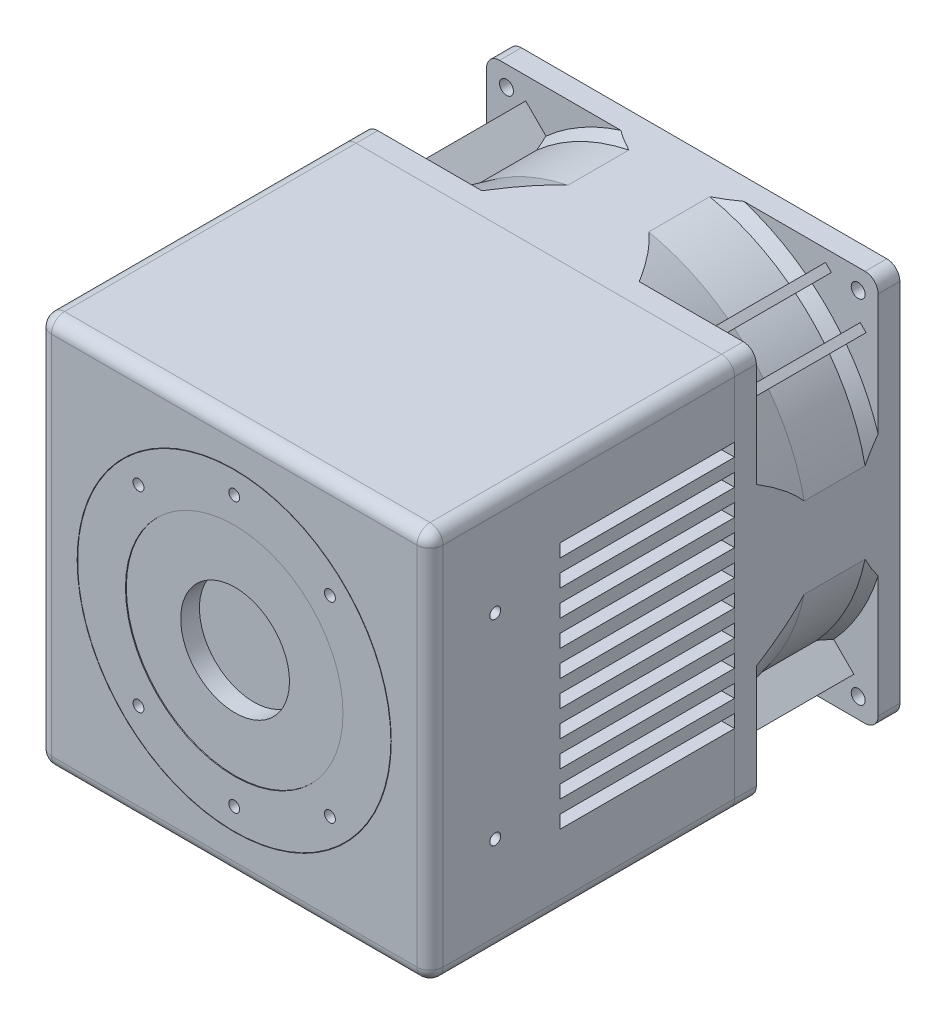
from build123d import *

# Parameters (mm, degrees)
EXTRUDE_1_DEPTH          = 70
SKETCH_4_W               = 40.152791685
SKETCH_4_H               = 3
CUT_EXTRUDE_1_DEPTH      = 89
SKETCH_5_R               = 1.25
CUT_EXTRUDE_2_DEPTH      = 8
SKETCH_6_R               = 1.25
CUT_EXTRUDE_4_DEPTH      = 12
FILLET_1_R               = 3
SKETCH_7_R               = 36.1
SKETCH_7_R_2             = 36
CUT_EXTRUDE_5_DEPTH      = 10
SKETCH_5_4_R             = 1.25
CUT_EXTRUDE_6_DEPTH      = 10
SKETCH_5_5_R             = 12.5
CUT_EXTRUDE_7_DEPTH      = 4.5
SKETCH_8_R               = 1.6
EXTRUDE_2_DEPTH          = 5
SKETCH_11_W              = 8.63890027
SKETCH_11_H              = 44.688652033
SKETCH_11_W_2            = 46.691504786
SKETCH_11_H_2            = 7.324528151
SKETCH_11_W_3            = 16.525132981
SKETCH_11_H_3            = 54.077024309
SKETCH_11_W_4            = 47.692931162
SKETCH_11_H_4            = 8.075597933
CUT_EXTRUDE_8_DEPTH      = 51
SKETCH_12_R              = 1.6
EXTRUDE_4_DEPTH          = 5
EXTRUDE_5_DEPTH          = 28
SKETCH_17_R              = 71.537562885
CUT_EXTRUDE_9_DEPTH      = 59
PATTERN_CIRCULAR_3_COUNT = 7
SKETCH_18_R              = 25
CUT_EXTRUDE_10_DEPTH     = 0.2


with BuildPart() as part:
    # Sketch 1 → Extrude 1 (new body)
    with BuildSketch(Plane.XY):
        with BuildLine():
            Line((-42, -45), (42, -45))
            ThreePointArc((42, -45), (44.121320344, -44.121320344), (45, -42))
            Line((45, -42), (45, 42))
            ThreePointArc((45, 42), (44.121320344, 44.121320344), (42, 45))
            Line((42, 45), (-42, 45))
            ThreePointArc((-42, 45), (-44.121320344, 44.121320344), (-45, 42))
            Line((-45, 42), (-45, -42))
            ThreePointArc((-45, -42), (-44.121320344, -44.121320344), (-42, -45))
        make_face()
    extrude(amount=EXTRUDE_1_DEPTH)

    # Sketch 4 → Cut-Extrude 1 (cut, symmetric)
    with BuildSketch(Plane(origin=(0, 0, 0), x_dir=(0, 0, -1), z_dir=(1, 0, 0))):
        with Locations((-20.076395843, 27.5)):
            Rectangle(SKETCH_4_W, SKETCH_4_H)
        with Locations((-20.076395843, 21.5)):
            Rectangle(SKETCH_4_W, SKETCH_4_H)
        with Locations((-20.076395843, 15.5)):
            Rectangle(SKETCH_4_W, SKETCH_4_H)
        with Locations((-20.076395843, 9.5)):
            Rectangle(SKETCH_4_W, SKETCH_4_H)
        with Locations((-20.076395843, 3.5)):
            Rectangle(SKETCH_4_W, SKETCH_4_H)
        with Locations((-20.076395843, -2.5)):
            Rectangle(SKETCH_4_W, SKETCH_4_H)
        with Locations((-20.076395843, -8.5)):
            Rectangle(SKETCH_4_W, SKETCH_4_H)
        with Locations((-20.076395843, -14.5)):
            Rectangle(SKETCH_4_W, SKETCH_4_H)
        with Locations((-20.076395843, -20.5)):
            Rectangle(SKETCH_4_W, SKETCH_4_H)
        with Locations((-20.076395843, -26.5)):
            Rectangle(SKETCH_4_W, SKETCH_4_H)
    extrude(amount=CUT_EXTRUDE_1_DEPTH, both=True, mode=Mode.SUBTRACT)

    # Sketch 5 → Cut-Extrude 2 (cut)
    with BuildSketch(Plane.XY.offset(70)):
        with Locations((0, 31)):
            Circle(SKETCH_5_R)
        with Locations((0, -31)):
            Circle(SKETCH_5_R)
    extrude(amount=-CUT_EXTRUDE_2_DEPTH, mode=Mode.SUBTRACT)

    # Sketch 6 → Cut-Extrude 4 (cut)
    with BuildSketch(Plane(origin=(45, 0, 0), x_dir=(0, 0, -1), z_dir=(1, 0, 0))):
        with Locations((-55, 22.5)):
            Circle(SKETCH_6_R)
        with Locations(Location((-55, -22.5, 0), (0, 0, 180))):  # turned: the seam where the file's is
            Circle(SKETCH_6_R)
    cut_extrude_4 = extrude(amount=-CUT_EXTRUDE_4_DEPTH, mode=Mode.SUBTRACT)

    # Mirror 1: Cut-Extrude 4 across plane
    add(cut_extrude_4.mirror(Plane(origin=(0, 0, 0), x_dir=(0, 0, 1), z_dir=(1, 0, 0))), mode=Mode.SUBTRACT)

    # Fillet 1
    fillet_1_edges = [part.edges().sort_by_distance(p)[0] for p in [
        (44.121320344, -44.121320344, 70),
        (45, 0, 70),
        (44.121320344, 44.121320344, 70),
        (0, 45, 70),
        (-44.121320344, 44.121320344, 70),
        (-45, 0, 70),
        (-44.121320344, -44.121320344, 70),
        (0, -45, 70),
    ]]
    fillet(fillet_1_edges, radius=FILLET_1_R)

    # Sketch 7 → Cut-Extrude 5 (cut)
    with BuildSketch(Plane.XY.offset(70)):
        Circle(SKETCH_7_R)
        Circle(SKETCH_7_R_2, mode=Mode.SUBTRACT)
    extrude(amount=-CUT_EXTRUDE_5_DEPTH, mode=Mode.SUBTRACT)

    # Sketch 5_4 → Cut-Extrude 6 (cut)
    with BuildSketch(Plane.XY.offset(70)):
        with Locations((-22, 22)):
            Circle(SKETCH_5_4_R)
        with Locations((22, 22)):
            Circle(SKETCH_5_4_R)
        with Locations((22, -22)):
            Circle(SKETCH_5_4_R)
        with Locations((-22, -22)):
            Circle(SKETCH_5_4_R)
    extrude(amount=-CUT_EXTRUDE_6_DEPTH, mode=Mode.SUBTRACT)

    # Sketch 5_5 → Cut-Extrude 7 (cut)
    with BuildSketch(Plane.XY.offset(70)):
        Circle(SKETCH_5_5_R)
    extrude(amount=-CUT_EXTRUDE_7_DEPTH, mode=Mode.SUBTRACT)

    # Sketch 18 → Cut-Extrude 10 (cut)
    with BuildSketch(Plane.XY.offset(70)):
        Circle(SKETCH_18_R)
    extrude(amount=-CUT_EXTRUDE_10_DEPTH, mode=Mode.SUBTRACT)


with BuildPart() as body_2:
    # Sketch 8 → Extrude 2 (new body)
    with BuildSketch(Plane(origin=(0, 0, 0), x_dir=(-1, 0, 0), z_dir=(0, 0, -1))):
        with BuildLine():
            Line((42, -45), (-42, -45))
            ThreePointArc((-42, -45), (-44.121320344, -44.121320344), (-45, -42))
            Line((-45, -42), (-45, 42))
            ThreePointArc((-45, 42), (-44.121320344, 44.121320344), (-42, 45))
            Line((-42, 45), (42, 45))
            ThreePointArc((42, 45), (44.121320344, 44.121320344), (45, 42))
            Line((45, 42), (45, -42))
            ThreePointArc((45, -42), (44.121320344, -44.121320344), (42, -45))
        make_face()
        with Locations((-40.415644678, 40.415644678)):
            Circle(SKETCH_8_R, mode=Mode.SUBTRACT)
        with Locations((40.415644678, 40.415644678)):
            Circle(SKETCH_8_R, mode=Mode.SUBTRACT)
        with Locations((40.415644678, -40.415644678)):
            Circle(SKETCH_8_R, mode=Mode.SUBTRACT)
        with Locations((-40.415644678, -40.415644678)):
            Circle(SKETCH_8_R, mode=Mode.SUBTRACT)
    extrude(amount=EXTRUDE_2_DEPTH)

    # Sketch 10 → Revolve 1 (revolve)
    with BuildSketch(Plane(origin=(0, 0, 0), x_dir=(1, 0, 0), z_dir=(0, 1, 0)), mode=Mode.PRIVATE) as revolve_1_sk:
        Polygon((0, 5), (-48.5, 5), (-45.948366204, 16), (-45.948366204, 30), (-47.165114324, 33), (0, 33), align=None)
    revolve(revolve_1_sk.sketch.rotate(Axis((0, 0, 0), (0, 0, -1)), 180), axis=Axis((0, 0, 0), (0, 0, -1)))  # turned: the seam where the file's is

    # Sketch 11 → Cut-Extrude 8 (cut)
    with BuildSketch(Plane.XY.offset(-5)):
        with Locations((-49.319450135, -0.187767446)):
            Rectangle(SKETCH_11_W, SKETCH_11_H)
        with Locations((-0.250356594, 48.662264076)):
            Rectangle(SKETCH_11_W_2, SKETCH_11_H_2)
        with Locations((53.262566491, 2.628744238)):
            Rectangle(SKETCH_11_W_3, SKETCH_11_H_3)
        with Locations((-0.751069782, -49.037798967)):
            Rectangle(SKETCH_11_W_4, SKETCH_11_H_4)
    extrude(amount=-CUT_EXTRUDE_8_DEPTH, mode=Mode.SUBTRACT)

    # Sketch 12 → Extrude 4 (add)
    with BuildSketch(Plane(origin=(0, 0, -33), x_dir=(-1, 0, 0), z_dir=(0, 0, -1))):
        with BuildLine():
            Line((-45, 42), (-45, -42))
            ThreePointArc((-45, -42), (-44.121320344, -44.121320344), (-42, -45))
            Line((-42, -45), (42, -45))
            ThreePointArc((42, -45), (44.121320344, -44.121320344), (45, -42))
            Line((45, -42), (45, 42))
            ThreePointArc((45, 42), (44.121320344, 44.121320344), (42, 45))
            Line((42, 45), (-42, 45))
            ThreePointArc((-42, 45), (-44.121320344, 44.121320344), (-45, 42))
        make_face()
        with Locations((-40.415644678, 40.415644678)):
            Circle(SKETCH_12_R, mode=Mode.SUBTRACT)
        with Locations((40.415644678, 40.415644678)):
            Circle(SKETCH_12_R, mode=Mode.SUBTRACT)
        with Locations((40.415644678, -40.415644678)):
            Circle(SKETCH_12_R, mode=Mode.SUBTRACT)
        with Locations((-40.415644678, -40.415644678)):
            Circle(SKETCH_12_R, mode=Mode.SUBTRACT)
    extrude(amount=EXTRUDE_4_DEPTH)

    # Sketch 13 → Cut-Revolve 1 (revolve, cut)
    with BuildSketch(Plane(origin=(0, 0, 0), x_dir=(1, 0, 0), z_dir=(0, 1, 0)), mode=Mode.PRIVATE) as cut_revolve_1_sk:
        Polygon((-42.53170407, 34.879231071), (-42.53170407, 40.263279466), (-20.192820642, 40.263279466), (-20.192820642, 3.87016557), (-43.629325082, 3.87016557), (-40.948366204, 15.427681268), (-40.948366204, 30.975371661), align=None)
    revolve(cut_revolve_1_sk.sketch.rotate(Axis((0, 0, 0), (0, 0, -1)), 180), axis=Axis((0, 0, 0), (0, 0, -1)), mode=Mode.SUBTRACT)  # turned: the seam where the file's is

    # Sketch 14 → Extrude 5 (add)
    with BuildSketch(Plane(origin=(0, 0, -5), x_dir=(-1, 0, 0), z_dir=(0, 0, -1))):
        Polygon((29.360510696, 33.269242064), (36.001520038, 39.910251406), (39.42163985, 36.490131595), (32.780630507, 29.849122252), align=None)
        Polygon((-27.189569209, 33.830038368), (-34.247789363, 40.888258522), (-32.908034612, 42.228013274), (-25.849814458, 35.16979312), align=None)
        Polygon((-35.16979312, 25.849814458), (-42.228013274, 32.908034612), (-40.888258522, 34.247789363), (-33.830038368, 27.189569209), align=None)
        Polygon((-29.360510696, -33.269242064), (-36.001520038, -39.910251406), (-39.42163985, -36.490131595), (-32.780630507, -29.849122252), align=None)
        Polygon((27.189569209, -33.830038368), (34.247789363, -40.888258522), (32.908034612, -42.228013274), (25.849814458, -35.16979312), align=None)
        Polygon((35.16979312, -25.849814458), (42.228013274, -32.908034612), (40.888258522, -34.247789363), (33.830038368, -27.189569209), align=None)
    extrude(amount=EXTRUDE_5_DEPTH)


with BuildPart() as body_3:
    # Sweep 2: sweep along a path in Sketch 16
    with BuildLine(Plane(origin=(0, 0, -25), x_dir=(-1, 0, 0), z_dir=(0, 0, -1))) as sweep_2_path:
        ThreePointArc((4.386661015, 13), (-46.962216222, 37.501000727), (-33.703696984, -17.827273218))
    # Sketch 15 → Sweep 2 (sweep)
    with BuildSketch(Plane(origin=(0, 13, 0), x_dir=(1, 0, 0), z_dir=(0, 1, 0))):
        with BuildLine():
            Line((13.950330621, 36.014020355), (13.607840572, 37.465965088))
            ThreePointArc((13.607840572, 37.465965088), (-4.838586066, 25.211118494), (-10.755988289, 3.87016557))
            Line((-10.755988289, 3.87016557), (-8.766518364, 4.075127561))
            ThreePointArc((-8.766518364, 4.075127561), (-3.427282846, 24.325780819), (13.950330621, 36.014020355))
        make_face()
    sweep(path=sweep_2_path.line)

    # Sketch 17 → Cut-Extrude 9 (cut)
    with BuildSketch(Plane(origin=(0, 0, -38), x_dir=(-1, 0, 0), z_dir=(0, 0, -1))):
        Circle(SKETCH_17_R)
        with BuildLine():
            Line((-33.51590231, 20.99186008), (0, -39.547109847))
            ThreePointArc((0, -39.547109847), (34.598708746, 19.15471875), (-33.51590231, 20.99186008))
        make_face(mode=Mode.SUBTRACT)
    extrude(amount=-CUT_EXTRUDE_9_DEPTH, mode=Mode.SUBTRACT)


with BuildPart() as pattern_circular_3_1:
    # Pattern Circular 3: pattern copy
    add(body_3.part.rotate(Axis((0, 0, 0), (0, 0, 1)), 1 * 360 / PATTERN_CIRCULAR_3_COUNT))


with BuildPart() as pattern_circular_3_2:
    # Pattern Circular 3: pattern copy
    add(body_3.part.rotate(Axis((0, 0, 0), (0, 0, 1)), 2 * 360 / PATTERN_CIRCULAR_3_COUNT))


with BuildPart() as pattern_circular_3_3:
    # Pattern Circular 3: pattern copy
    add(body_3.part.rotate(Axis((0, 0, 0), (0, 0, 1)), 3 * 360 / PATTERN_CIRCULAR_3_COUNT))


with BuildPart() as pattern_circular_3_4:
    # Pattern Circular 3: pattern copy
    add(body_3.part.rotate(Axis((0, 0, 0), (0, 0, 1)), 4 * 360 / PATTERN_CIRCULAR_3_COUNT))


with BuildPart() as pattern_circular_3_5:
    # Pattern Circular 3: pattern copy
    add(body_3.part.rotate(Axis((0, 0, 0), (0, 0, 1)), 5 * 360 / PATTERN_CIRCULAR_3_COUNT))


with BuildPart() as pattern_circular_3_6:
    # Pattern Circular 3: pattern copy
    add(body_3.part.rotate(Axis((0, 0, 0), (0, 0, 1)), 6 * 360 / PATTERN_CIRCULAR_3_COUNT))


solid = Compound([part.part, body_2.part, body_3.part, pattern_circular_3_1.part, pattern_circular_3_2.part, pattern_circular_3_3.part, pattern_circular_3_4.part, pattern_circular_3_5.part, pattern_circular_3_6.part])
